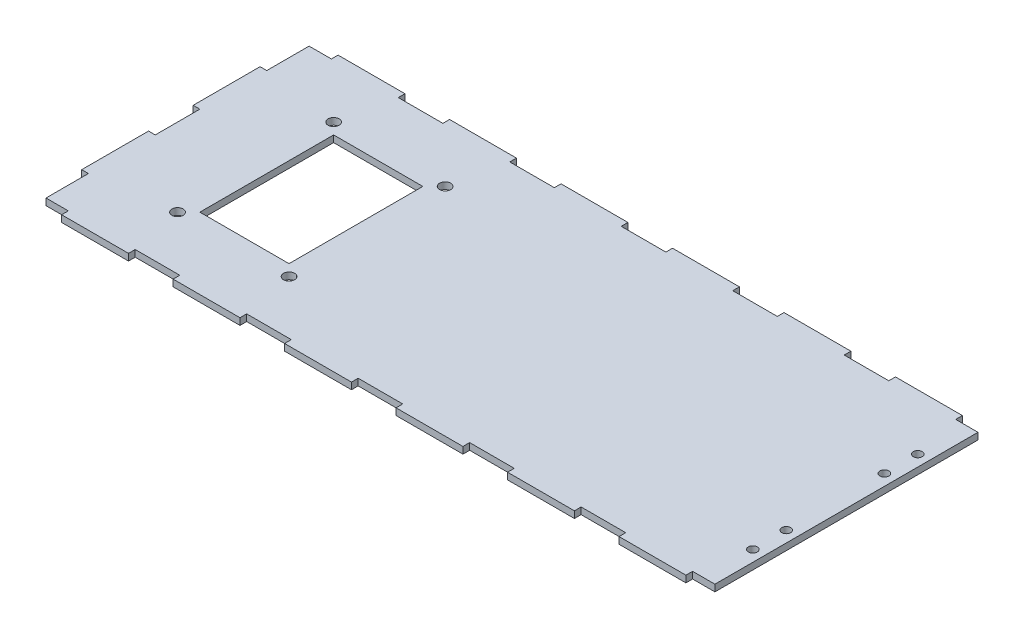
from build123d import *

# Parameters (mm, degrees)
EXTRUDE_1_DEPTH     = 3
SKETCH_5_R          = 2
SKETCH_5_R_2        = 2.5
SKETCH_5_W          = 40
SKETCH_5_H          = 60
CUT_EXTRUDE_1_DEPTH = 3


with BuildPart() as part:
    # 草图4 → 凸台-拉伸1 (new body)
    with BuildSketch(Plane(origin=(0, 0, 0), x_dir=(1, 0, 0), z_dir=(0, 1, 0))):
        Polygon((10, 0), (0, 0), (0, -19), (-3, -19), (-3, -49), (0, -49), (0, -69), (-3, -69), (-3, -99), (0, -99), (0, -118), (10, -118), (10, -121), (40, -121), (40, -118), (60, -118), (60, -121), (90, -121), (90, -118), (110, -118), (110, -121), (140, -121), (140, -118), (160, -118), (160, -121), (190, -121), (190, -118), (210, -118), (210, -121), (240, -121), (240, -118), (260, -118), (260, -121), (290, -121), (290, -118), (300, -118), (300, 0), (290, 0), (290, 3), (260, 3), (260, 0), (240, 0), (240, 3), (210, 3), (210, 0), (190, 0), (190, 3), (160, 3), (160, 0), (140, 0), (140, 3), (110, 3), (110, 0), (90, 0), (90, 3), (60, 3), (60, 0), (40, 0), (40, 3), (10, 3), align=None)
    extrude(amount=-EXTRUDE_1_DEPTH)

    # 草图5 → 切除-拉伸1 (cut)
    with BuildSketch(Plane(origin=(0, 0, 0), x_dir=(1, 0, 0), z_dir=(0, 1, 0))):
        with Locations((295, -96)):
            Circle(SKETCH_5_R)
        with Locations((295, -81)):
            Circle(SKETCH_5_R)
        with Locations((295, -22)):
            Circle(SKETCH_5_R)
        with Locations((295, -37)):
            Circle(SKETCH_5_R)
        with Locations((35, -24)):
            Circle(SKETCH_5_R_2)
        with Locations((35, -94)):
            Circle(SKETCH_5_R_2)
        with Locations((85, -94)):
            Circle(SKETCH_5_R_2)
        with Locations((85, -24)):
            Circle(SKETCH_5_R_2)
        with Locations((60, -59)):
            Rectangle(SKETCH_5_W, SKETCH_5_H)
    extrude(amount=-CUT_EXTRUDE_1_DEPTH, mode=Mode.SUBTRACT)


solid = part.part
